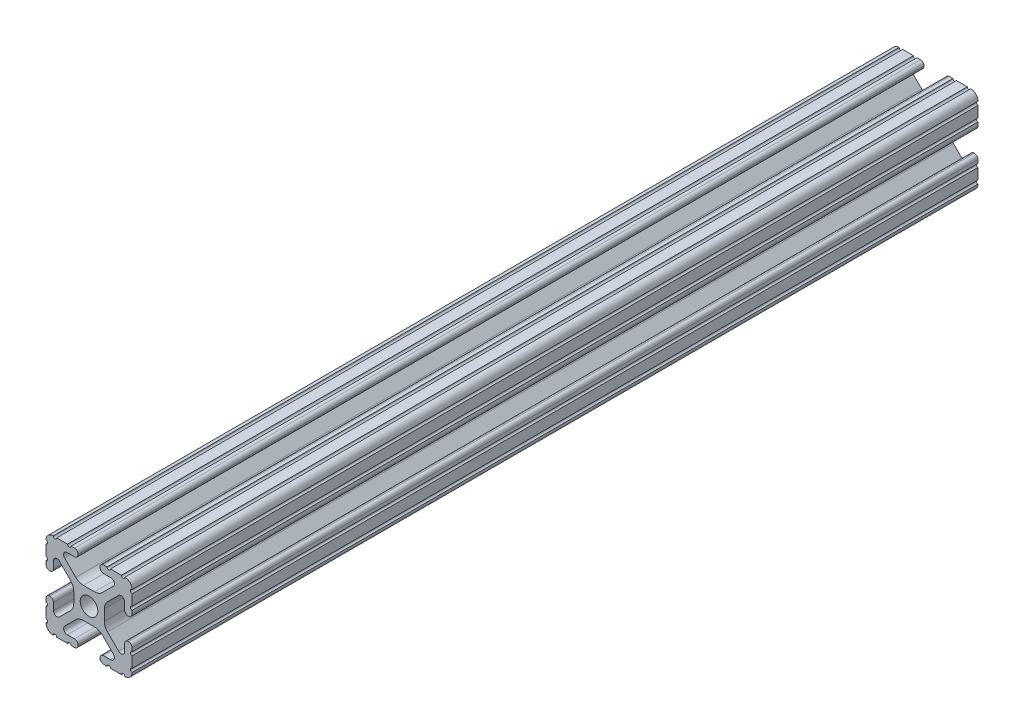
from build123d import *

# Parameters (mm, degrees)
SKETCH1_R               = 2.6035
BOSS_EXTRUDE1_DEPTH     = 304.8
SKETCH2_W               = 362.658607085
SKETCH2_H               = 27.642551573
CUT_EXTRUDE1_DEPTH      = 7.112
CUT_EXTRUDE1_DEPTH_BACK = 30.734


with BuildPart() as part:
    # Sketch1 → Boss-Extrude1 (new body, symmetric)
    with BuildSketch(Plane.XY):
        with BuildLine():
            Line((-7.179650497, -8.645192506), (-3.952270251, -5.423690499))
            ThreePointArc((-3.952270251, -5.423690499), (-2.922936451, -4.736929036), (-1.709253557, -4.4958))
            Line((-1.709253557, -4.4958), (1.709253557, -4.4958))
            ThreePointArc((1.709253557, -4.4958), (2.922936451, -4.736929036), (3.952270251, -5.423690499))
            Line((3.952270251, -5.423690499), (7.179650497, -8.645192506))
            ThreePointArc((7.179650497, -8.645192506), (7.41473083, -9.822813117), (6.416408329, -10.4902))
            Line((6.416408329, -10.4902), (4.287512407, -10.4902))
            ThreePointArc((4.287512407, -10.4902), (3.54574862, -10.79744862), (3.2385, -11.539212407))
            Line((3.2385, -11.539212407), (3.2385, -11.650987593))
            ThreePointArc((3.2385, -11.650987593), (3.54574862, -12.39275138), (4.287512407, -12.7))
            Line((4.287512407, -12.7), (5.317126718, -12.7))
            ThreePointArc((5.317126718, -12.7), (5.825126718, -12.192), (6.333126718, -12.7))
            Line((6.333126718, -12.7), (9.550443118, -12.7))
            ThreePointArc((9.550443118, -12.7), (10.058366869, -12.192000006), (10.566443095, -12.699847501))
            ThreePointArc((10.566443095, -12.699847501), (12.082537762, -12.08250727), (12.699846982, -10.566399977))
            ThreePointArc((12.699846982, -10.566399977), (12.192000006, -10.058323491), (12.7, -9.5504))
            Line((12.7, -9.5504), (12.7, -6.3330836))
            ThreePointArc((12.7, -6.3330836), (12.192, -5.8250836), (12.7, -5.3170836))
            Line((12.7, -5.3170836), (12.7, -4.287469289))
            ThreePointArc((12.7, -4.287469289), (12.39275138, -3.545705502), (11.650987593, -3.238456882))
            Line((11.650987593, -3.238456882), (11.539212407, -3.238456882))
            ThreePointArc((11.539212407, -3.238456882), (10.79744862, -3.545705502), (10.4902, -4.287469289))
            Line((10.4902, -4.287469289), (10.4902, -6.402089023))
            ThreePointArc((10.4902, -6.402089023), (9.856505071, -7.351067942), (8.737131347, -7.129408934))
            Line((8.737131347, -7.129408934), (5.441005833, -3.840816462))
            ThreePointArc((5.441005833, -3.840816462), (4.750877967, -2.809883091), (4.5085, -1.593185507))
            Line((4.5085, -1.593185507), (4.5085, 1.593185507))
            ThreePointArc((4.5085, 1.593185507), (4.750877967, 2.809883091), (5.441005833, 3.840816462))
            Line((5.441005833, 3.840816462), (8.737131347, 7.129408934))
            ThreePointArc((8.737131347, 7.129408934), (9.856505071, 7.351067942), (10.4902, 6.402089023))
            Line((10.4902, 6.402089023), (10.4902, 4.287469289))
            ThreePointArc((10.4902, 4.287469289), (10.79744862, 3.545705502), (11.539212407, 3.238456882))
            Line((11.539212407, 3.238456882), (11.650987593, 3.238456882))
            ThreePointArc((11.650987593, 3.238456882), (12.39275138, 3.545705502), (12.7, 4.287469289))
            Line((12.7, 4.287469289), (12.7, 5.3170836))
            ThreePointArc((12.7, 5.3170836), (12.192, 5.8250836), (12.7, 6.3330836))
            Line((12.7, 6.3330836), (12.7, 9.5504))
            ThreePointArc((12.7, 9.5504), (12.192000006, 10.058323491), (12.699846982, 10.566399977))
            ThreePointArc((12.699846982, 10.566399977), (12.082537762, 12.08250727), (10.566443095, 12.699847501))
            ThreePointArc((10.566443095, 12.699847501), (10.058366869, 12.192000006), (9.550443118, 12.7))
            Line((9.550443118, 12.7), (6.333126718, 12.7))
            ThreePointArc((6.333126718, 12.7), (5.825126718, 12.192), (5.317126718, 12.7))
            Line((5.317126718, 12.7), (4.287512407, 12.7))
            ThreePointArc((4.287512407, 12.7), (3.54574862, 12.39275138), (3.2385, 11.650987593))
            Line((3.2385, 11.650987593), (3.2385, 11.539212407))
            ThreePointArc((3.2385, 11.539212407), (3.54574862, 10.79744862), (4.287512407, 10.4902))
            Line((4.287512407, 10.4902), (6.476788598, 10.4902))
            ThreePointArc((6.476788598, 10.4902), (7.432222385, 9.85140422), (7.207036008, 8.724370562))
            Line((7.207036008, 8.724370562), (3.898272566, 5.423169045))
            ThreePointArc((3.898272566, 5.423169045), (2.869120213, 4.736787962), (1.655778399, 4.4958))
            Line((1.655778399, 4.4958), (-1.655778399, 4.4958))
            ThreePointArc((-1.655778399, 4.4958), (-2.869120213, 4.736787962), (-3.898272566, 5.423169045))
            Line((-3.898272566, 5.423169045), (-7.207036008, 8.724370562))
            ThreePointArc((-7.207036008, 8.724370562), (-7.432222385, 9.85140422), (-6.476788598, 10.4902))
            Line((-6.476788598, 10.4902), (-4.287512407, 10.4902))
            ThreePointArc((-4.287512407, 10.4902), (-3.54574862, 10.79744862), (-3.2385, 11.539212407))
            Line((-3.2385, 11.539212407), (-3.2385, 11.650987593))
            ThreePointArc((-3.2385, 11.650987593), (-3.54574862, 12.39275138), (-4.287512407, 12.7))
            Line((-4.287512407, 12.7), (-5.317126718, 12.7))
            ThreePointArc((-5.317126718, 12.7), (-5.825126718, 12.192), (-6.333126718, 12.7))
            Line((-6.333126718, 12.7), (-9.550443118, 12.7))
            ThreePointArc((-9.550443118, 12.7), (-10.058366869, 12.192000006), (-10.566443095, 12.699847501))
            ThreePointArc((-10.566443095, 12.699847501), (-12.082537762, 12.08250727), (-12.699846982, 10.566399977))
            ThreePointArc((-12.699846982, 10.566399977), (-12.192000006, 10.058323491), (-12.7, 9.5504))
            Line((-12.7, 9.5504), (-12.7, 6.3330836))
            ThreePointArc((-12.7, 6.3330836), (-12.192, 5.8250836), (-12.7, 5.3170836))
            Line((-12.7, 5.3170836), (-12.7, 4.287469289))
            ThreePointArc((-12.7, 4.287469289), (-12.39275138, 3.545705502), (-11.650987593, 3.238456882))
            Line((-11.650987593, 3.238456882), (-11.539212407, 3.238456882))
            ThreePointArc((-11.539212407, 3.238456882), (-10.79744862, 3.545705502), (-10.4902, 4.287469289))
            Line((-10.4902, 4.287469289), (-10.4902, 6.402089023))
            ThreePointArc((-10.4902, 6.402089023), (-9.856505071, 7.351067942), (-8.737131347, 7.129408934))
            Line((-8.737131347, 7.129408934), (-5.441005833, 3.840816462))
            ThreePointArc((-5.441005833, 3.840816462), (-4.750877967, 2.809883091), (-4.5085, 1.593185507))
            Line((-4.5085, 1.593185507), (-4.5085, -1.593185507))
            ThreePointArc((-4.5085, -1.593185507), (-4.750877967, -2.809883091), (-5.441005833, -3.840816462))
            Line((-5.441005833, -3.840816462), (-8.737131347, -7.129408934))
            ThreePointArc((-8.737131347, -7.129408934), (-9.856505071, -7.351067942), (-10.4902, -6.402089023))
            Line((-10.4902, -6.402089023), (-10.4902, -4.287469289))
            ThreePointArc((-10.4902, -4.287469289), (-10.79744862, -3.545705502), (-11.539212407, -3.238456882))
            Line((-11.539212407, -3.238456882), (-11.650987593, -3.238456882))
            ThreePointArc((-11.650987593, -3.238456882), (-12.39275138, -3.545705502), (-12.7, -4.287469289))
            Line((-12.7, -4.287469289), (-12.7, -5.3170836))
            ThreePointArc((-12.7, -5.3170836), (-12.192, -5.8250836), (-12.7, -6.3330836))
            Line((-12.7, -6.3330836), (-12.7, -9.5504))
            ThreePointArc((-12.7, -9.5504), (-12.192000006, -10.058323491), (-12.699846982, -10.566399977))
            ThreePointArc((-12.699846982, -10.566399977), (-12.082537762, -12.08250727), (-10.566443095, -12.699847501))
            ThreePointArc((-10.566443095, -12.699847501), (-10.058366869, -12.192000006), (-9.550443118, -12.7))
            Line((-9.550443118, -12.7), (-6.333126718, -12.7))
            ThreePointArc((-6.333126718, -12.7), (-5.825126718, -12.192), (-5.317126718, -12.7))
            Line((-5.317126718, -12.7), (-4.287512407, -12.7))
            ThreePointArc((-4.287512407, -12.7), (-3.54574862, -12.39275138), (-3.2385, -11.650987593))
            Line((-3.2385, -11.650987593), (-3.2385, -11.539212407))
            ThreePointArc((-3.2385, -11.539212407), (-3.54574862, -10.79744862), (-4.287512407, -10.4902))
            Line((-4.287512407, -10.4902), (-6.416408329, -10.4902))
            ThreePointArc((-6.416408329, -10.4902), (-7.41473083, -9.822813117), (-7.179650497, -8.645192506))
        make_face()
        Circle(SKETCH1_R, mode=Mode.SUBTRACT)
    extrude(amount=BOSS_EXTRUDE1_DEPTH, both=True)

    # Sketch2 → Cut-Extrude1 (cut, two sides)
    with BuildSketch(Plane(origin=(12.7, 0, 0), x_dir=(0, 0, -1), z_dir=(1, 0, 0))) as cut_extrude1_sk:
        with Locations((126.205743533, -0.275832689)):
            Rectangle(SKETCH2_W, SKETCH2_H)
    extrude(amount=CUT_EXTRUDE1_DEPTH, mode=Mode.SUBTRACT)
    extrude(cut_extrude1_sk.sketch, amount=-CUT_EXTRUDE1_DEPTH_BACK, mode=Mode.SUBTRACT)


solid = part.part
